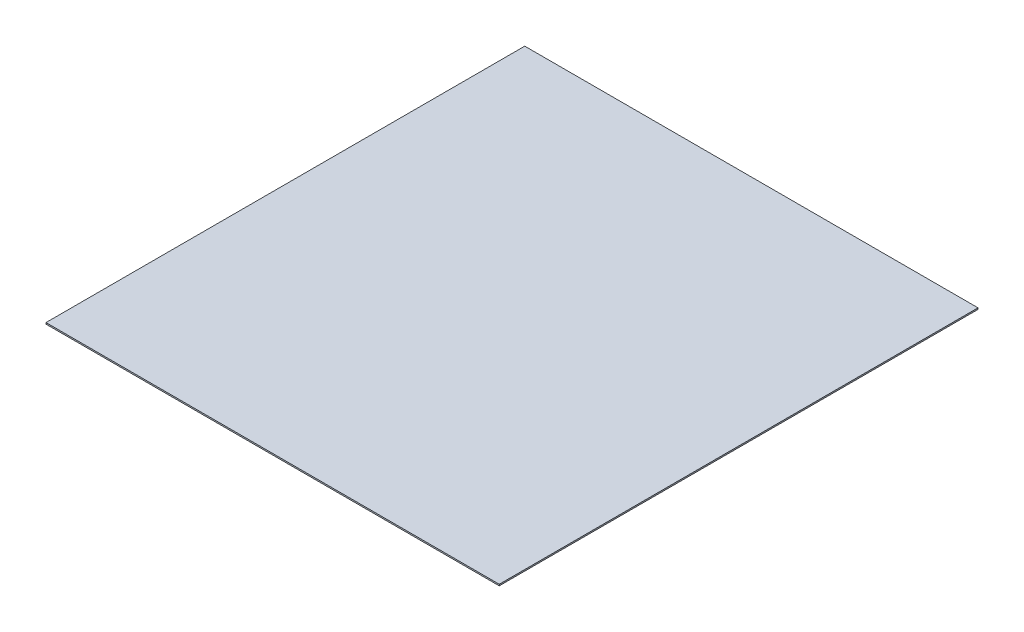
from build123d import *

# Parameters (mm, degrees)
SKETCH1_W           = 1016
SKETCH1_H           = 1073.15
BOSS_EXTRUDE1_DEPTH = 3.175


with BuildPart() as part:
    # Sketch1 → Boss-Extrude1 (new body)
    with BuildSketch(Plane(origin=(0, 0, 0), x_dir=(1, 0, 0), z_dir=(0, 1, 0))):
        with Locations((508, 536.575)):
            Rectangle(SKETCH1_W, SKETCH1_H)
    extrude(amount=BOSS_EXTRUDE1_DEPTH)


solid = part.part
